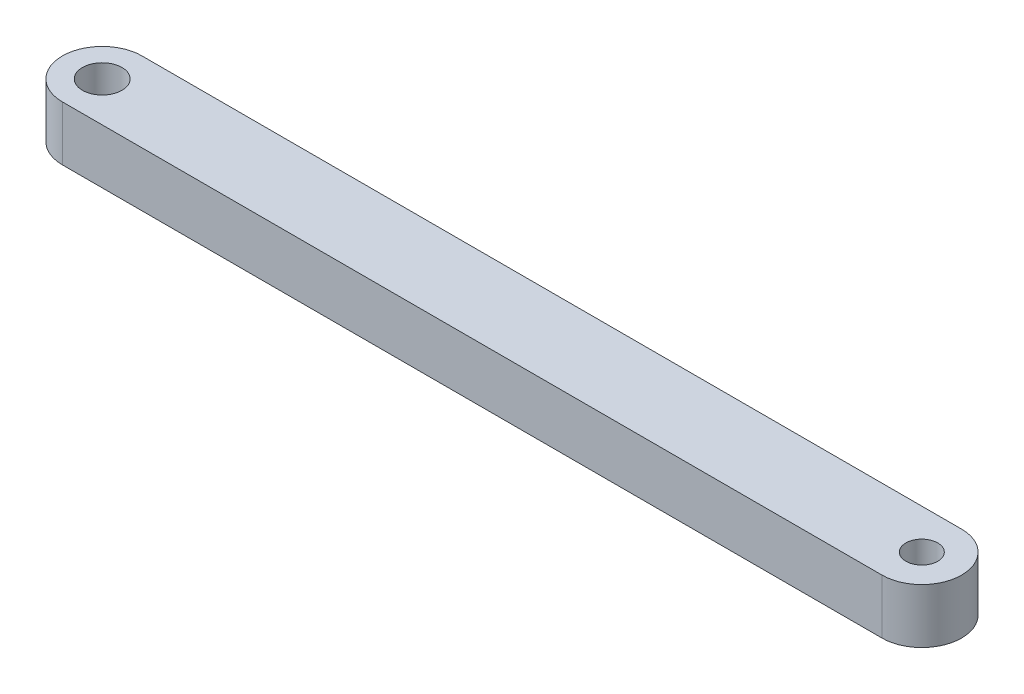
from build123d import *

# Parameters (mm, degrees)
SKETCH1_R           = 0.8636
SKETCH1_R_2         = 1.07315
BOSS_EXTRUDE1_DEPTH = 2.9591


with BuildPart() as part:
    # Sketch1 → Boss-Extrude1 (new body)
    with BuildSketch(Plane(origin=(0, 0, 0), x_dir=(1, 0, 0), z_dir=(0, 1, 0))):
        with BuildLine():
            Line((-22.225, 2.159), (22.225, 2.159))
            ThreePointArc((22.225, 2.159), (24.384, 0), (22.225, -2.159))
            Line((22.225, -2.159), (-22.225, -2.159))
            ThreePointArc((-22.225, -2.159), (-24.384, 0), (-22.225, 2.159))
        make_face()
        with Locations((22.225, 0)):
            Circle(SKETCH1_R, mode=Mode.SUBTRACT)
        with Locations((-22.225, 0)):
            Circle(SKETCH1_R_2, mode=Mode.SUBTRACT)
    extrude(amount=BOSS_EXTRUDE1_DEPTH)


solid = part.part
